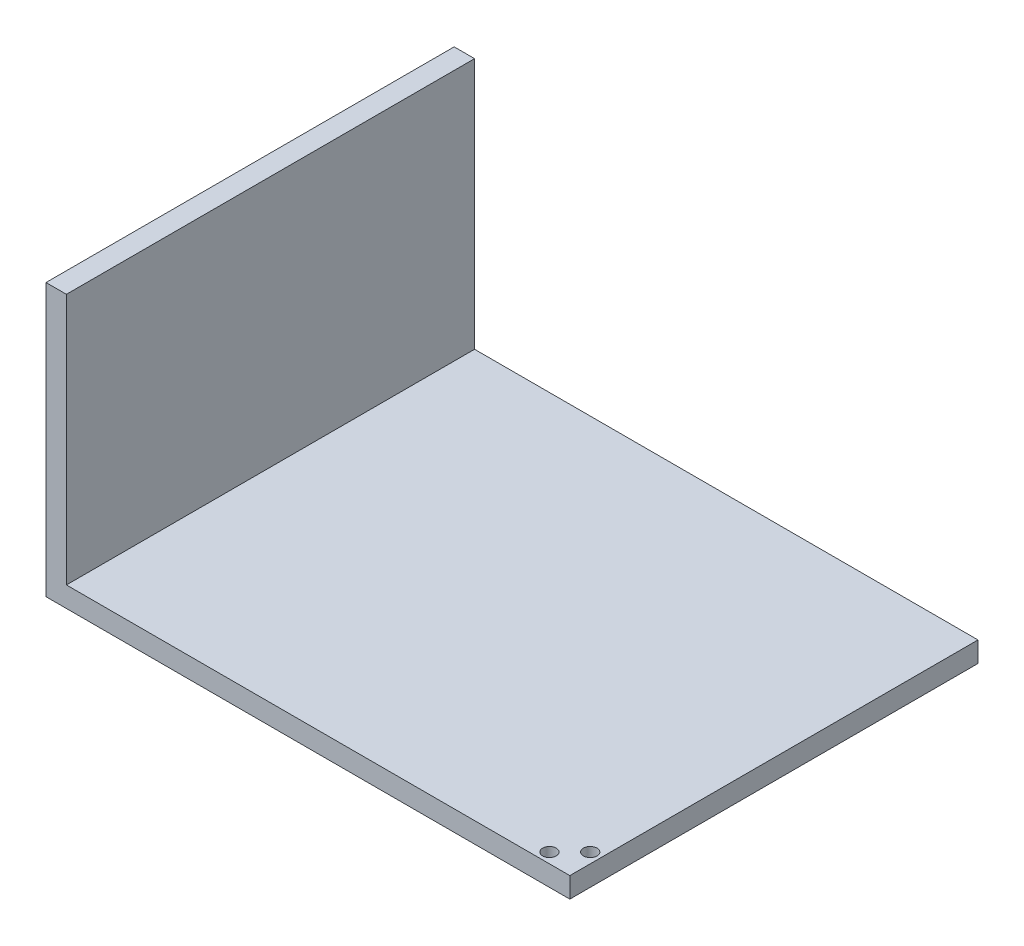
from build123d import *

# Parameters (mm, degrees)
SKETCH1_W           = 192.5
SKETCH1_H           = 150
BOSS_EXTRUDE1_DEPTH = 7.5
SKETCH2_W           = 7.5
SKETCH2_H           = 150
BOSS_EXTRUDE2_DEPTH = 92.5
SKETCH3_R           = 2.5
CUT_EXTRUDE1_DEPTH  = 92.5


with BuildPart() as part:
    # Sketch1 → Boss-Extrude1 (new body)
    with BuildSketch(Plane(origin=(0, 0, 0), x_dir=(1, 0, 0), z_dir=(0, 1, 0))):
        with Locations((103.75, 75)):
            Rectangle(SKETCH1_W, SKETCH1_H)
    extrude(amount=BOSS_EXTRUDE1_DEPTH)

    # Sketch2 → Boss-Extrude2 (add)
    with BuildSketch(Plane(origin=(0, 7.5, 0), x_dir=(1, 0, 0), z_dir=(0, 1, 0))):
        with Locations((11.25, 75)):
            Rectangle(SKETCH2_W, SKETCH2_H)
    extrude(amount=BOSS_EXTRUDE2_DEPTH)

    # Sketch3 → Cut-Extrude1 (cut)
    with BuildSketch(Plane.XZ):
        with Locations((188.75, -3.75)):
            Circle(SKETCH3_R)
        with Locations((196.25, -11.25)):
            Circle(SKETCH3_R)
    extrude(amount=-CUT_EXTRUDE1_DEPTH, mode=Mode.SUBTRACT)


solid = part.part
